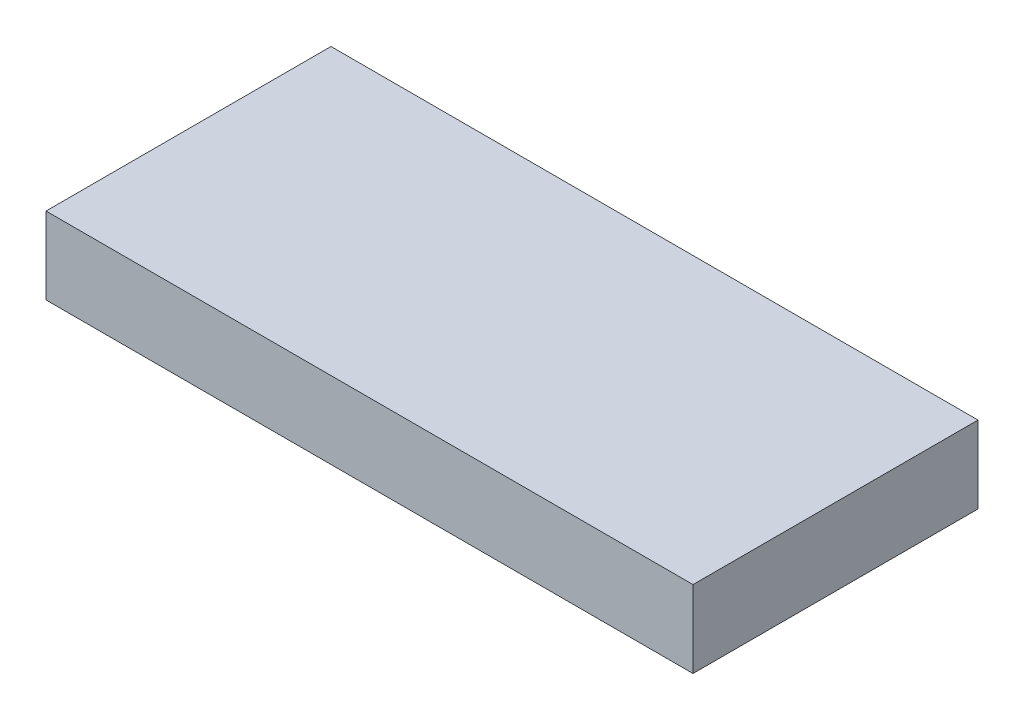
from build123d import *

# Parameters (mm, degrees)
SKETCH_1_W      = 42
SKETCH_1_H      = 18.5
EXTRUDE_1_DEPTH = 5


with BuildPart() as part:
    # Эскиз1 → Бобышка-Вытянуть1 (new body)
    with BuildSketch(Plane(origin=(0, 0, 0), x_dir=(1, 0, 0), z_dir=(0, 1, 0))):
        with Locations((21, 9.25)):
            Rectangle(SKETCH_1_W, SKETCH_1_H)
    extrude(amount=EXTRUDE_1_DEPTH)


solid = part.part
